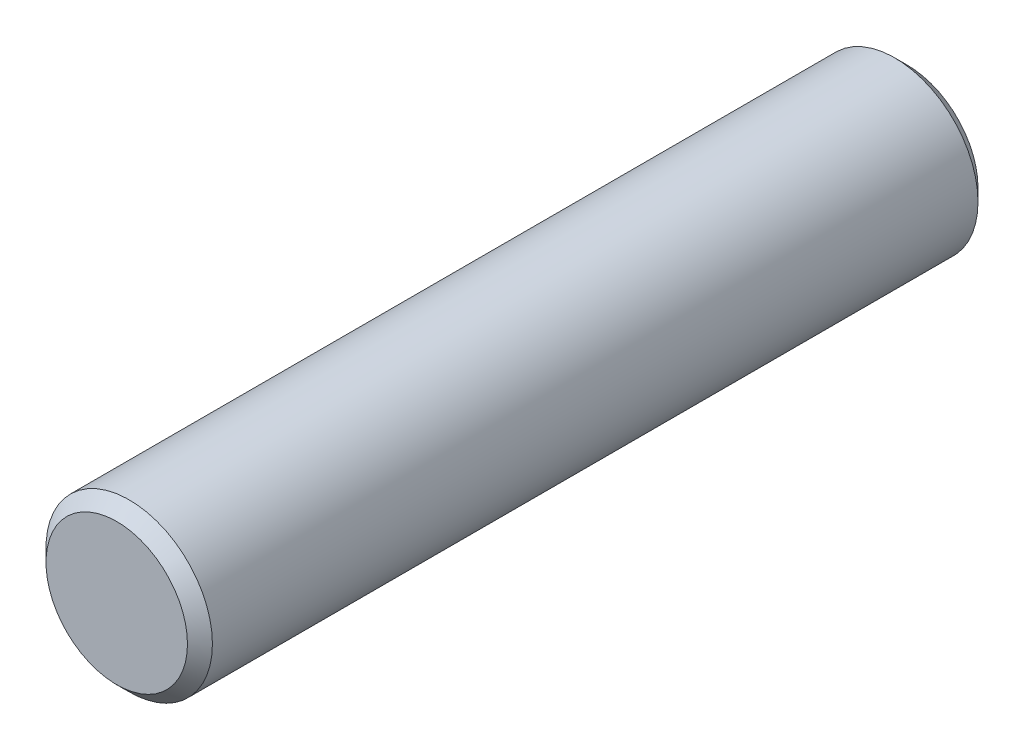
from build123d import *

# Parameters (mm, degrees)
SKETCH1_R           = 4
BOSS_EXTRUDE1_DEPTH = 38
CHAMFER1_SIZE       = 0.6


with BuildPart() as part:
    # Sketch1 → Boss-Extrude1 (new body)
    with BuildSketch(Plane.XY):
        Circle(SKETCH1_R)
    extrude(amount=BOSS_EXTRUDE1_DEPTH)

    # Chamfer1
    chamfer1_edges = [part.edges().sort_by_distance(p)[0] for p in [
        (-4, 0, 0),
        (-4, 0, 38),
    ]]
    chamfer(chamfer1_edges, length=CHAMFER1_SIZE)


solid = part.part
